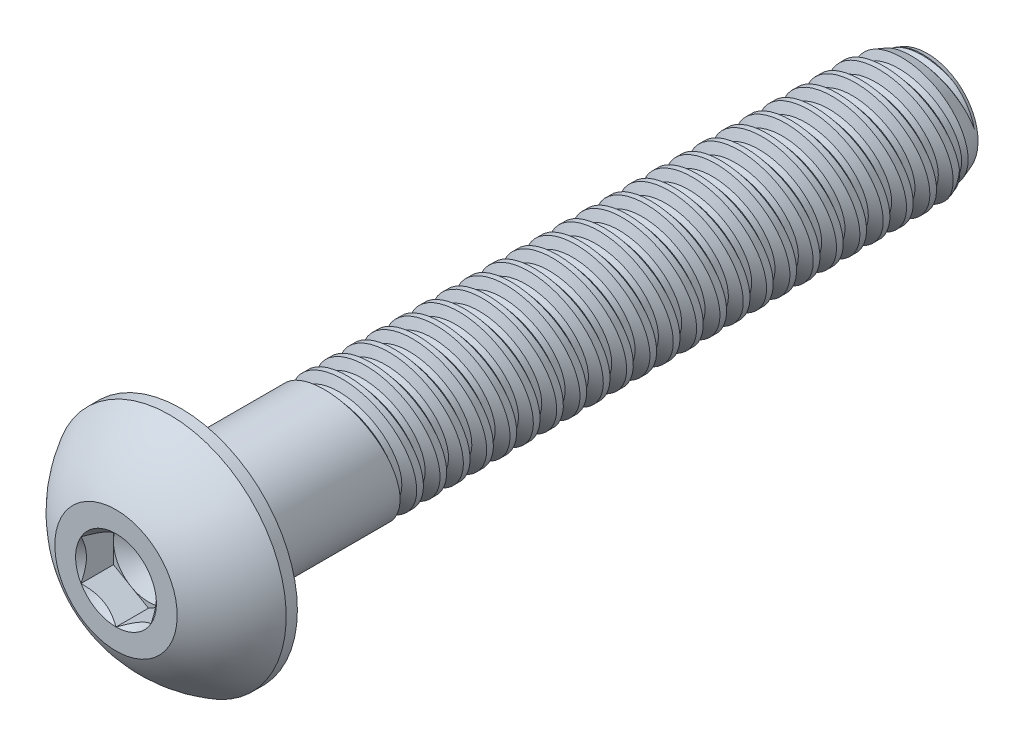
from build123d import *

# Parameters (mm, degrees)
SKETCH1_W          = 25.4
SKETCH1_H          = 2.0828
LPATTERN1_COUNT    = 26
LPATTERN1_PITCH    = 0.79375
SKETCH4_R          = 3.9624
EXTRUDE1_DEPTH     = 2.2098
CUT_EXTRUDE1_DEPTH = 1.1049
SKETCH7_R          = 1.374815329
CUT_EXTRUDE4_DEPTH = 1.1049
CUT_EXTRUDE4_DRAFT = -45
SKETCH8_R          = 1.190625
CUT_EXTRUDE5_DEPTH = 0.3683
CUT_EXTRUDE5_DRAFT = -60


with BuildPart() as part:
    # Sketch1 → Revolve1 (revolve)
    with BuildSketch(Plane(origin=(0, 0, 0), x_dir=(0, 0, -1), z_dir=(1, 0, 0)), mode=Mode.PRIVATE) as revolve1_sk:
        with Locations((12.7, 1.0414)):
            Rectangle(SKETCH1_W, SKETCH1_H)
    revolve(revolve1_sk.sketch.rotate(Axis((0, 0, 0), (0, 0, 1)), 143.466023127), axis=Axis((0, 0, 0), (0, 0, 1)))

    # Sketch2 → Cut-Revolve1 (revolve, cut)
    with BuildSketch(Plane(origin=(0, 0, 0), x_dir=(0, 0, -1), z_dir=(1, 0, 0)), mode=Mode.PRIVATE) as cut_revolve1_sk:
        Polygon((4.859965104, 2.101371857), (5.542220832, 2.231374854), (5.37897657, 1.762908932), (5.184046362, 1.725765218), align=None)
    cut_revolve1 = revolve(cut_revolve1_sk.sketch.rotate(Axis((0, -0.162231854, -4.7625), (0, 0.18718091792156177, -0.9823254572523517)), 180), axis=Axis((0, -0.162231854, -4.7625), (0, 0.18718091792156177, -0.9823254572523517)), mode=Mode.SUBTRACT)

    # Sketch3 → Cut-Revolve2 (revolve, cut)
    with BuildSketch(Plane(origin=(0, 0, 0), x_dir=(0, 0, -1), z_dir=(1, 0, 0)), mode=Mode.PRIVATE) as cut_revolve2_sk:
        Polygon((25.4, 1.725765218), (24.419055, 2.0828), (25.4, 2.0828), align=None)
    revolve(cut_revolve2_sk.sketch.rotate(Axis((0, 0, -24.419055), (0, 0, 1)), 143.466023127), axis=Axis((0, 0, -24.419055), (0, 0, 1)), mode=Mode.SUBTRACT)

    # LPattern1: Cut-Revolve1 ×26
    with Locations(*[(0, 0, -i * LPATTERN1_PITCH) for i in range(1, LPATTERN1_COUNT)]):
        add(cut_revolve1, mode=Mode.SUBTRACT)

    # Sketch4 → Extrude1 (add)
    with BuildSketch(Plane.XY):
        with Locations(Location((0, 0, 0), (0, 0, 90))):
            Circle(SKETCH4_R)
    extrude(amount=EXTRUDE1_DEPTH)

    # Sketch9 → Cut-Revolve3 (revolve, cut)
    with BuildSketch(Plane(origin=(0, 0, 0), x_dir=(0, 0, -1), z_dir=(1, 0, 0))):
        with BuildLine():
            Line((0, 3.9624), (-0.381, 3.9624))
            ThreePointArc((-0.381, 3.9624), (-1.434442989, 3.157885071), (-2.2098, 2.0828))
            Line((-2.2098, 2.0828), (-2.5908, 2.0828))
            Line((-2.5908, 2.0828), (-2.5908, 4.3434))
            Line((-2.5908, 4.3434), (0, 4.3434))
            Line((0, 4.3434), (0, 3.9624))
        make_face()
    revolve(axis=Axis((0, 0, 0), (0, 0, 1)), mode=Mode.SUBTRACT)

    # Sketch6 → Cut-Extrude1 (cut)
    with BuildSketch(Plane.XY.offset(2.2098)):
        Polygon((0, -1.374815329), (1.190625, -0.687407664), (1.190625, 0.687407664), (0, 1.374815329), (-1.190625, 0.687407664), (-1.190625, -0.687407664), align=None)
    extrude(amount=-CUT_EXTRUDE1_DEPTH, mode=Mode.SUBTRACT)


with BuildPart() as cut_extrude4_tool:
    # Sketch7 → Cut-Extrude4 (with draft: the straight prism first)
    with BuildSketch(Plane.XY.offset(2.2098)):
        Circle(SKETCH7_R)
    extrude(amount=-CUT_EXTRUDE4_DEPTH)
    # Cut-Extrude4: the draft: its side faces are tilted about the plane it starts from
    cut_extrude4_sides = [cut_extrude4_tool.faces().sort_by_distance(p)[0] for p in [
        (-1.374815329, 0, 1.65735),
    ]]
    draft(cut_extrude4_sides, Plane.XY.offset(2.2098), CUT_EXTRUDE4_DRAFT)


with BuildPart() as part_1:
    add(part.part)

    # Cut-Extrude4: cut by cut_extrude4_tool
    add(cut_extrude4_tool.part, mode=Mode.SUBTRACT)


with BuildPart() as cut_extrude5_tool:
    # Sketch8 → Cut-Extrude5 (with draft: the straight prism first)
    with BuildSketch(Plane.XY.offset(1.1049)):
        Circle(SKETCH8_R)
    extrude(amount=-CUT_EXTRUDE5_DEPTH)
    # Cut-Extrude5: the draft: its side faces are tilted about the plane it starts from
    cut_extrude5_sides = [cut_extrude5_tool.faces().sort_by_distance(p)[0] for p in [
        (-1.190625, 0, 0.92075),
    ]]
    draft(cut_extrude5_sides, Plane.XY.offset(1.1049), CUT_EXTRUDE5_DRAFT)


with BuildPart() as part_2:
    add(part_1.part)

    # Cut-Extrude5: cut by cut_extrude5_tool
    add(cut_extrude5_tool.part, mode=Mode.SUBTRACT)


solid = part_2.part
